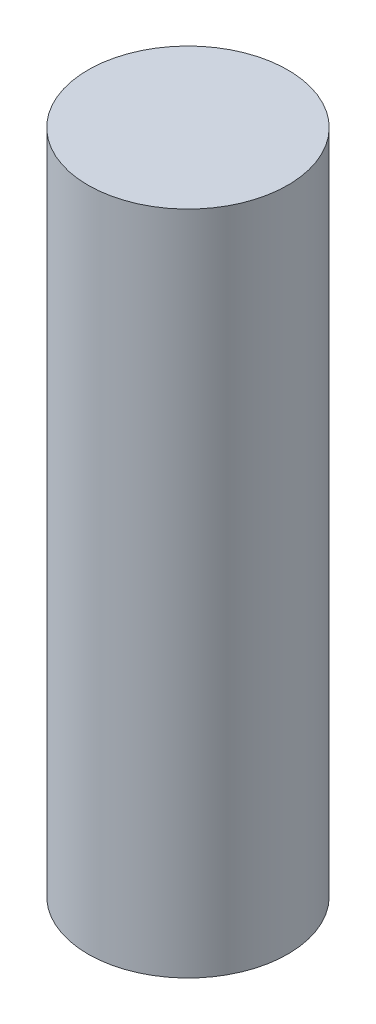
from build123d import *

# Parameters (mm, degrees)
SKETCH1_R           = 9.525
BOSS_EXTRUDE1_DEPTH = 63.5


with BuildPart() as part:
    # Sketch1 → Boss-Extrude1 (new body)
    with BuildSketch(Plane(origin=(0, 0, 0), x_dir=(1, 0, 0), z_dir=(0, 1, 0))):
        Circle(SKETCH1_R)
    extrude(amount=BOSS_EXTRUDE1_DEPTH)


solid = part.part
